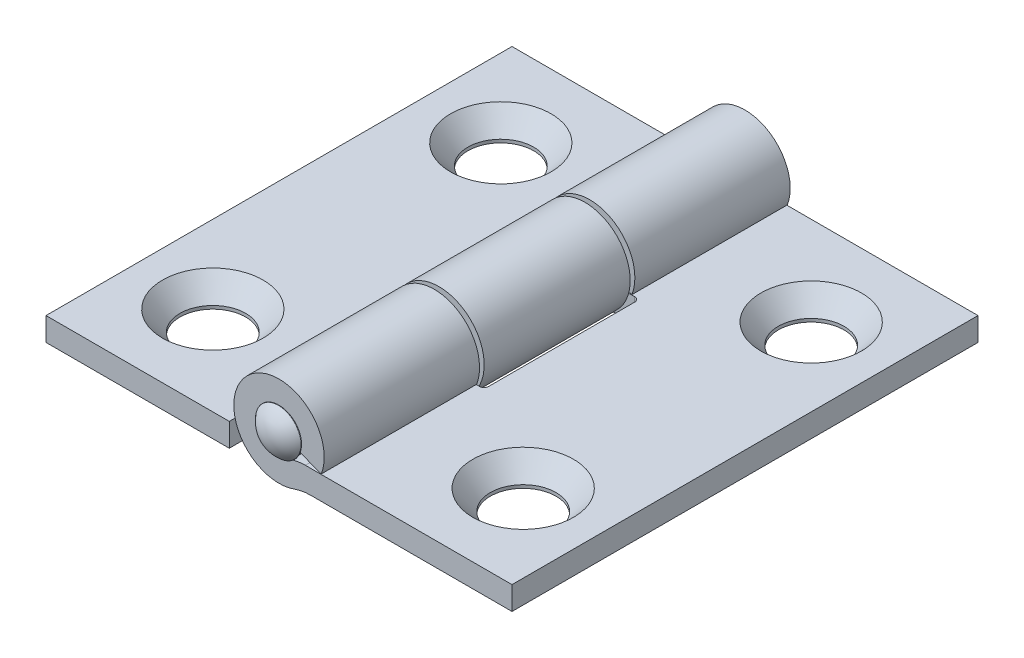
from build123d import *

# Parameters (mm, degrees)
BOSS_EXTRUDE1_DEPTH      = 12.7
BOSS_EXTRUDE1_DEPTH_BACK = 12.7
SKETCH6_R                = 1.7907
CUT_EXTRUDE1_DEPTH       = 2.54
SKETCH11_R               = 2.7432
CUT_EXTRUDE5_DEPTH       = 2.571552736
CUT_EXTRUDE5_TAPER       = 41
SKETCH8_W                = 5.42036
SKETCH8_H                = 8.466666666
CUT_EXTRUDE2_DEPTH       = 5.626047264
CUT_EXTRUDE2_DEPTH_BACK  = 1.301552736
SKETCH12_W               = 5.42036
SKETCH12_H               = 8.720666667
CUT_EXTRUDE6_DEPTH       = 4.356047264
CUT_EXTRUDE6_DEPTH_BACK  = 2.571552736
FILLET1_R                = 0.254
FILLET2_R                = 0.254


with BuildPart() as part:
    # Sketch4 → Boss-Extrude1 (new body, two sides)
    with BuildSketch(Plane.XY) as boss_extrude1_sk:
        with BuildLine():
            Line((12.7, -2.162247264), (12.7, -0.892247264))
            Line((12.7, -0.892247264), (1.437450496, -0.892247264))
            ThreePointArc((1.437450496, -0.892247264), (0.937045899, -0.942027346), (0.456255618, -1.089416367))
            ThreePointArc((0.456255618, -1.089416367), (-0.850505265, 0.819535237), (1.105583556, -0.415550492))
            Line((1.105583556, -0.415550492), (2.306271073, -0.866847264))
            ThreePointArc((2.306271073, -0.866847264), (-1.732922364, 1.751368185), (0.842380579, -2.315319719))
            ThreePointArc((0.842380579, -2.315319719), (1.269903724, -2.200808082), (1.710814166, -2.162247264))
            Line((1.710814166, -2.162247264), (12.7, -2.162247264))
        make_face()
    extrude(amount=BOSS_EXTRUDE1_DEPTH)
    extrude(boss_extrude1_sk.sketch, amount=-BOSS_EXTRUDE1_DEPTH_BACK)

    # Sketch6 → Cut-Extrude1 (cut)
    with BuildSketch(Plane(origin=(0, -0.892247264, 0), x_dir=(1, 0, 0), z_dir=(0, 1, 0))):
        with Locations((8.4582, -7.8486)):
            Circle(SKETCH6_R)
        with Locations((8.4582, 7.8486)):
            Circle(SKETCH6_R)
    extrude(amount=-CUT_EXTRUDE1_DEPTH, mode=Mode.SUBTRACT)

    # Sketch11 → Cut-Extrude5 (cut, through all)
    with BuildSketch(Plane(origin=(0, -0.892247264, 0), x_dir=(1, 0, 0), z_dir=(0, 1, 0))):
        with Locations((8.4582, 7.8486)):
            Circle(SKETCH11_R)
        with Locations((8.4582, -7.8486)):
            Circle(SKETCH11_R)
    extrude(amount=-CUT_EXTRUDE5_DEPTH, taper=CUT_EXTRUDE5_TAPER, mode=Mode.SUBTRACT)


with BuildPart() as body_2:
    # Sketch5 → Revolve1 (revolve)
    with BuildSketch(Plane(origin=(0, 0, 0), x_dir=(1, 0, 0), z_dir=(0, 1, 0))):
        with BuildLine():
            ThreePointArc((-1.237948381, 12.741300813), (-1.241043616, 12.714416391), (-1.218141207, 12.7))
            Line((-1.218141207, 12.7), (-1.1811, 12.7))
            Line((-1.1811, 12.7), (-1.1811, -12.7))
            Line((-1.1811, -12.7), (-1.218141207, -12.7))
            ThreePointArc((-1.218141207, -12.7), (-1.241043616, -12.714416391), (-1.237948381, -12.741300813))
            ThreePointArc((-1.237948381, -12.741300813), (-0.686475586, -13.178900545), (0, -13.335))
            Line((0, -13.335), (0, 13.335))
            ThreePointArc((0, 13.335), (-0.686475586, 13.178900545), (-1.237948381, 12.741300813))
        make_face()
    revolve(axis=Axis((0, 0, -13.335), (0, 0, 1)))


with BuildPart() as body_3:
    # Mirror1: mirrored copy
    add(part.part.mirror(Plane(origin=(0, 0, 0), x_dir=(0, 0, 1), z_dir=(1, 0, 0))))

    # Sketch12 → Cut-Extrude6 (cut, two sides)
    with BuildSketch(Plane(origin=(0, -0.892247264, 0), x_dir=(1, 0, 0), z_dir=(0, 1, 0))) as cut_extrude6_sk:
        with Locations((0, 8.339666667)):
            Rectangle(SKETCH12_W, SKETCH12_H)
        with Locations((0, -8.339666667)):
            Rectangle(SKETCH12_W, SKETCH12_H)
    extrude(amount=CUT_EXTRUDE6_DEPTH, mode=Mode.SUBTRACT)
    extrude(cut_extrude6_sk.sketch, amount=-CUT_EXTRUDE6_DEPTH_BACK, mode=Mode.SUBTRACT)

    # Fillet1
    fillet1_edges = [body_3.edges().sort_by_distance(p)[0] for p in [
        (-2.71018, -1.527247264, 3.979333333),
        (-2.71018, -1.527247264, -3.979333333),
    ]]
    fillet(fillet1_edges, radius=FILLET1_R)


with BuildPart() as part_1:
    add(part.part)

    # Sketch8 → Cut-Extrude2 (cut, two sides)
    with BuildSketch(Plane(origin=(0, -2.162247264, 0), x_dir=(1, 0, 0), z_dir=(0, 1, 0))) as cut_extrude2_sk:
        Rectangle(SKETCH8_W, SKETCH8_H)
    extrude(amount=CUT_EXTRUDE2_DEPTH, mode=Mode.SUBTRACT)
    extrude(cut_extrude2_sk.sketch, amount=-CUT_EXTRUDE2_DEPTH_BACK, mode=Mode.SUBTRACT)

    # Fillet2
    fillet2_edges = [part_1.edges().sort_by_distance(p)[0] for p in [
        (2.71018, -1.527247264, -4.233333333),
        (2.71018, -1.527247264, 4.233333333),
    ]]
    fillet(fillet2_edges, radius=FILLET2_R)


solid = Compound([body_2.part, body_3.part, part_1.part])
